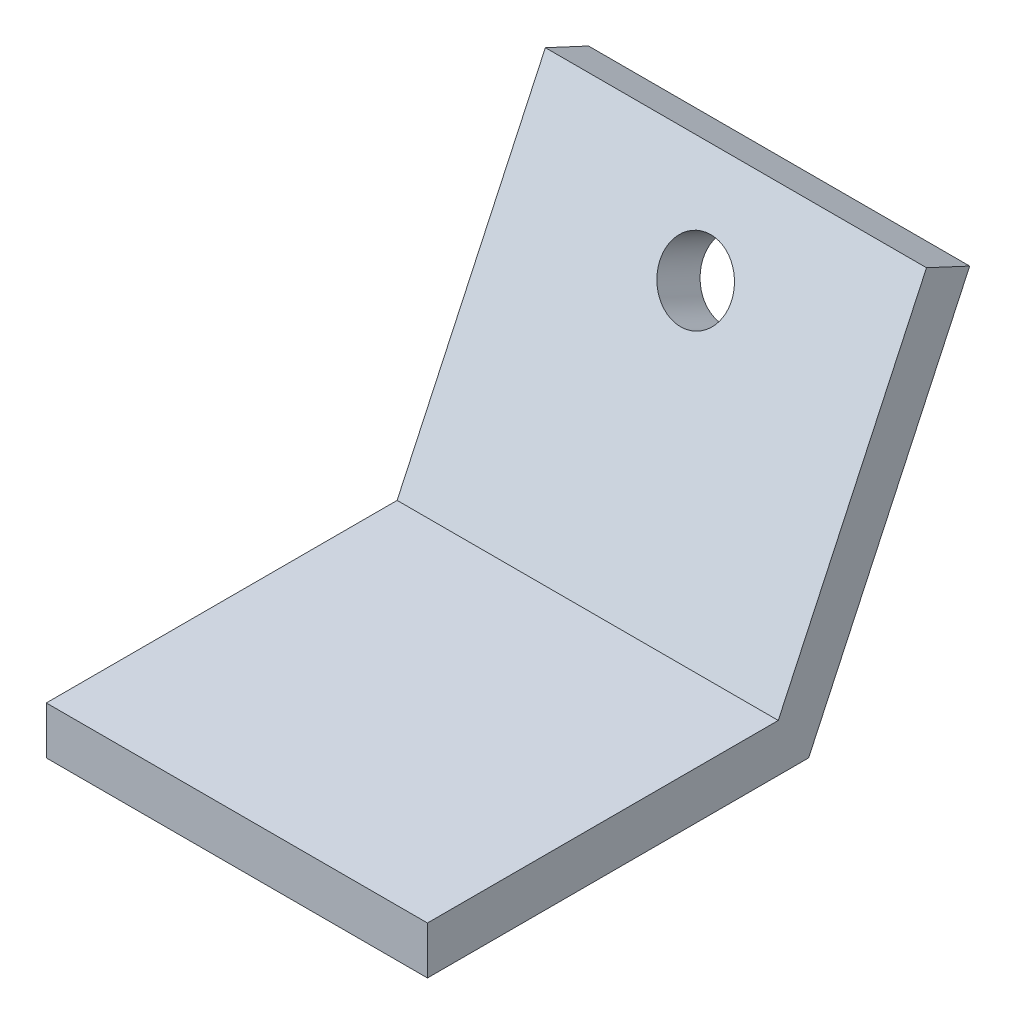
from build123d import *

# Parameters (mm, degrees)
BOSS_EXTRUDE2_DEPTH = 50.8
CUT_EXTRUDE1_REACH  = 68.632
SKETCH3_R           = 4.7625
SKETCH4_R           = 4.7625
BOSS_EXTRUDE3_DEPTH = 12.7


with BuildPart() as part:
    # Sketch2 → Boss-Extrude2 (new body)
    with BuildSketch(Plane(origin=(0, 0, 0), x_dir=(0, 0, -1), z_dir=(1, 0, 0))):
        Polygon((-25.4, 0), (25.4, 0), (46.869007696, 46.040435581), (41.113953249, 48.724061544), (21.354603844, 6.35), (-25.4, 6.35), align=None)
    extrude(amount=BOSS_EXTRUDE2_DEPTH)

    # Sketch3 → Cut-Extrude1 (cut, up to next)
    with BuildSketch(Plane(origin=(0, -9.728764428, -20.863402643), x_dir=(1, 0, 0), z_dir=(0, -0.422618262, -0.906307787)), mode=Mode.PRIVATE) as cut_extrude1_sk1:
        with Locations((25.4, -48.834503848)):
            Circle(SKETCH3_R)
    cut_extrude1_tool1 = extrude(cut_extrude1_sk1.sketch, amount=-CUT_EXTRUDE1_REACH, mode=Mode.PRIVATE) & part.part
    add(cut_extrude1_tool1.solids().sort_by_distance((25.4, 34.530327, -41.501756))[0], mode=Mode.SUBTRACT)

    # Sketch4 → Boss-Extrude3 (add)
    with BuildSketch(Plane.XZ):
        with Locations((25.4, 0)):
            Circle(SKETCH4_R)
    extrude(amount=BOSS_EXTRUDE3_DEPTH)


solid = part.part
